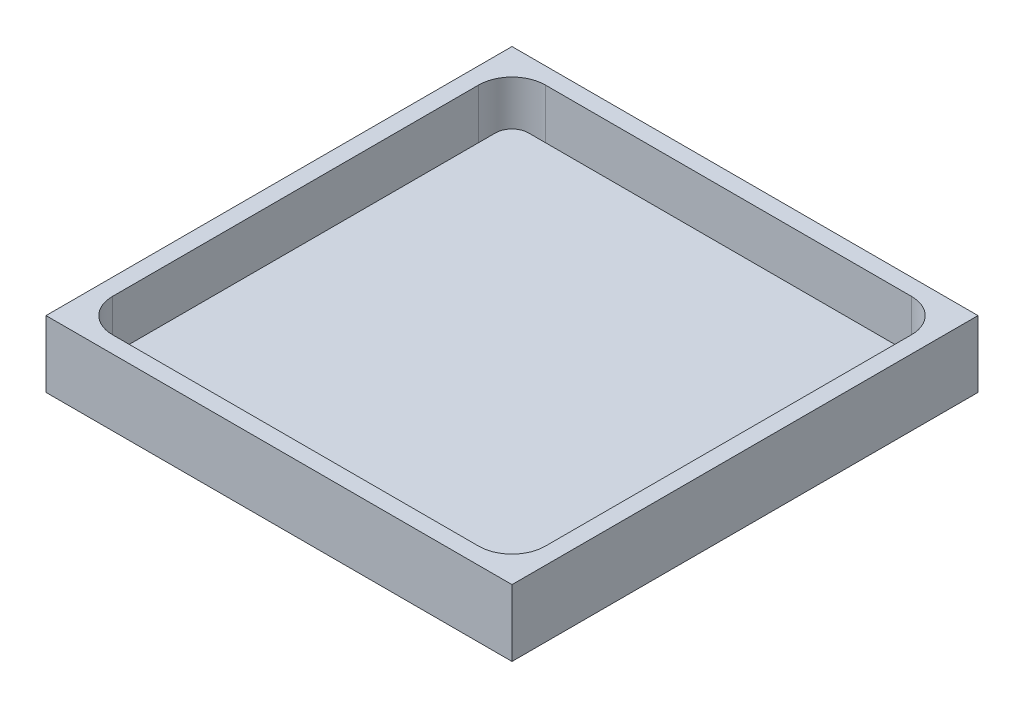
from build123d import *

# Parameters (mm, degrees)
SKETCH1_W           = 26
SKETCH1_H           = 26
SKETCH1_W_2         = 24
SKETCH1_H_2         = 24
BOSS_EXTRUDE1_DEPTH = 1
SKETCH1_3_W         = 24
SKETCH1_3_H         = 24
BOSS_EXTRUDE2_DEPTH = 2
SKETCH1_4_W         = 28
SKETCH1_4_H         = 28
SKETCH1_4_W_2       = 26
SKETCH1_4_H_2       = 26
BOSS_EXTRUDE3_DEPTH = 4
FILLET1_R           = 1
FILLET2_R           = 2


with BuildPart() as part:
    # Sketch1 → Boss-Extrude1 (new body)
    with BuildSketch(Plane(origin=(0, 0, 0), x_dir=(1, 0, 0), z_dir=(0, 1, 0))):
        Rectangle(SKETCH1_W, SKETCH1_H)
        Rectangle(SKETCH1_W_2, SKETCH1_H_2, mode=Mode.SUBTRACT)
    extrude(amount=BOSS_EXTRUDE1_DEPTH)

    # Sketch1_3 → Boss-Extrude2 (add)
    with BuildSketch(Plane(origin=(0, 0, 0), x_dir=(1, 0, 0), z_dir=(0, 1, 0))):
        Rectangle(SKETCH1_3_W, SKETCH1_3_H)
    extrude(amount=BOSS_EXTRUDE2_DEPTH)

    # Sketch1_4 → Boss-Extrude3 (add)
    with BuildSketch(Plane(origin=(0, 0, 0), x_dir=(1, 0, 0), z_dir=(0, 1, 0))):
        Rectangle(SKETCH1_4_W, SKETCH1_4_H)
        Rectangle(SKETCH1_4_W_2, SKETCH1_4_H_2, mode=Mode.SUBTRACT)
    extrude(amount=BOSS_EXTRUDE3_DEPTH)

    # Fillet1
    fillet1_edges = [part.edges().sort_by_distance(p)[0] for p in [
        (12, 1.5, -12),
        (12, 1.5, 12),
        (-12, 1.5, -12),
        (-12, 1.5, 12),
    ]]
    fillet(fillet1_edges, radius=FILLET1_R)

    # Fillet2
    fillet2_edges = [part.edges().sort_by_distance(p)[0] for p in [
        (-13, 2.5, -13),
        (13, 2.5, -13),
        (13, 2.5, 13),
        (-13, 2.5, 13),
    ]]
    fillet(fillet2_edges, radius=FILLET2_R)


solid = part.part
